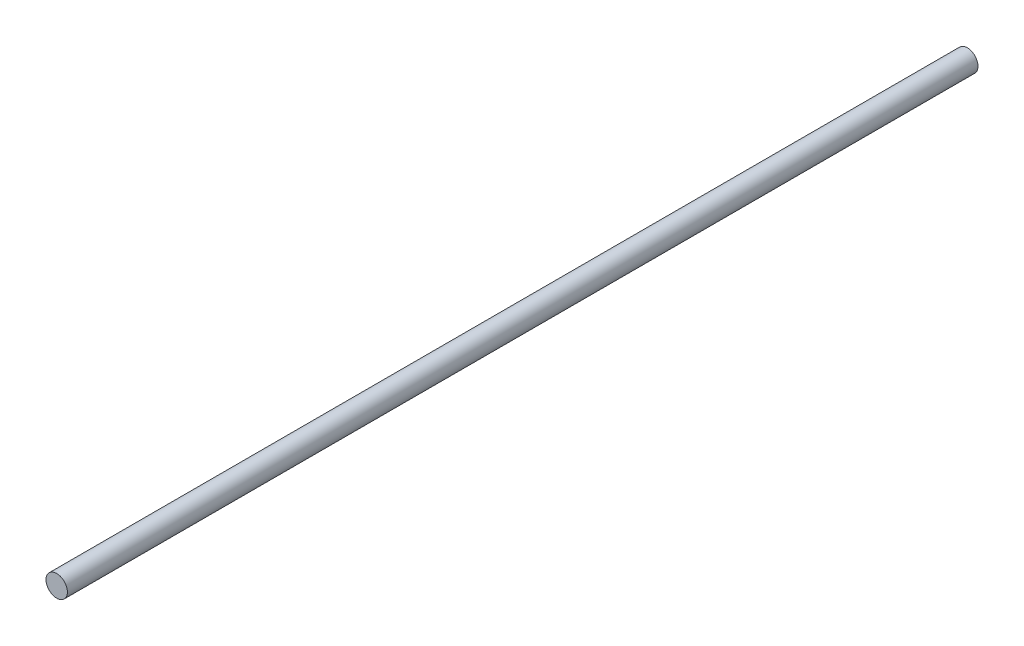
from build123d import *

# Parameters (mm, degrees)
SKETCH1_R           = 5
BOSS_EXTRUDE1_DEPTH = 212.5


with BuildPart() as part:
    # Sketch1 → Boss-Extrude1 (new body, symmetric)
    with BuildSketch(Plane.XY):
        Circle(SKETCH1_R)
    extrude(amount=BOSS_EXTRUDE1_DEPTH, both=True)


solid = part.part
